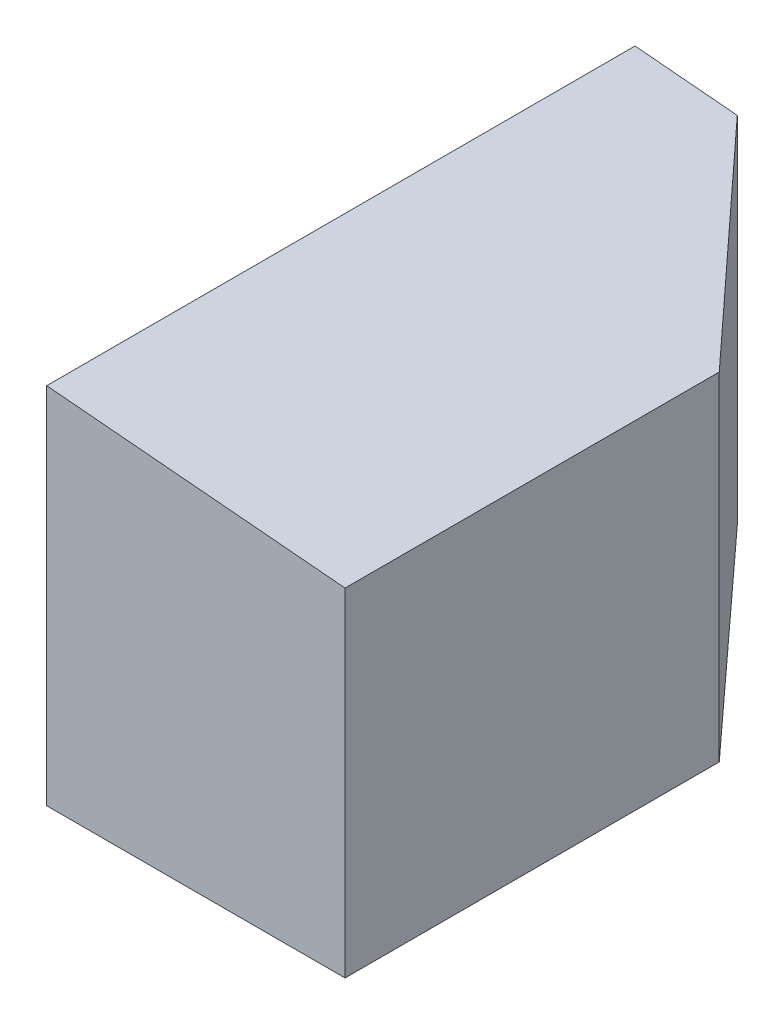
from build123d import *

# Parameters (mm, degrees)
AUFSATZ_LINEAR_AUSTRAGEN1_DEPTH = 3048.54
SCHNITT_LINEAR_AUSTRAGEN1_DEPTH = 4931


with BuildPart() as part:
    # Skizze1 → Aufsatz-Linear austragen1 (new body)
    with BuildSketch(Plane(origin=(0, 0, 0), x_dir=(1, 0, 0), z_dir=(0, 1, 0))):
        Polygon((-2500, 4930), (-2500, 0), (0, 0), (0, 3135.547559896), (-1643.224828015, 4930), align=None)
    extrude(amount=AUFSATZ_LINEAR_AUSTRAGEN1_DEPTH)

    # Skizze2 → Schnitt-Linear austragen1 (cut, through all)
    with BuildSketch(Plane.XY):
        Polygon((-2500, 3048.54), (0, 2829.818341185), (0, 3048.54), align=None)
    extrude(amount=-SCHNITT_LINEAR_AUSTRAGEN1_DEPTH, mode=Mode.SUBTRACT)


solid = part.part
